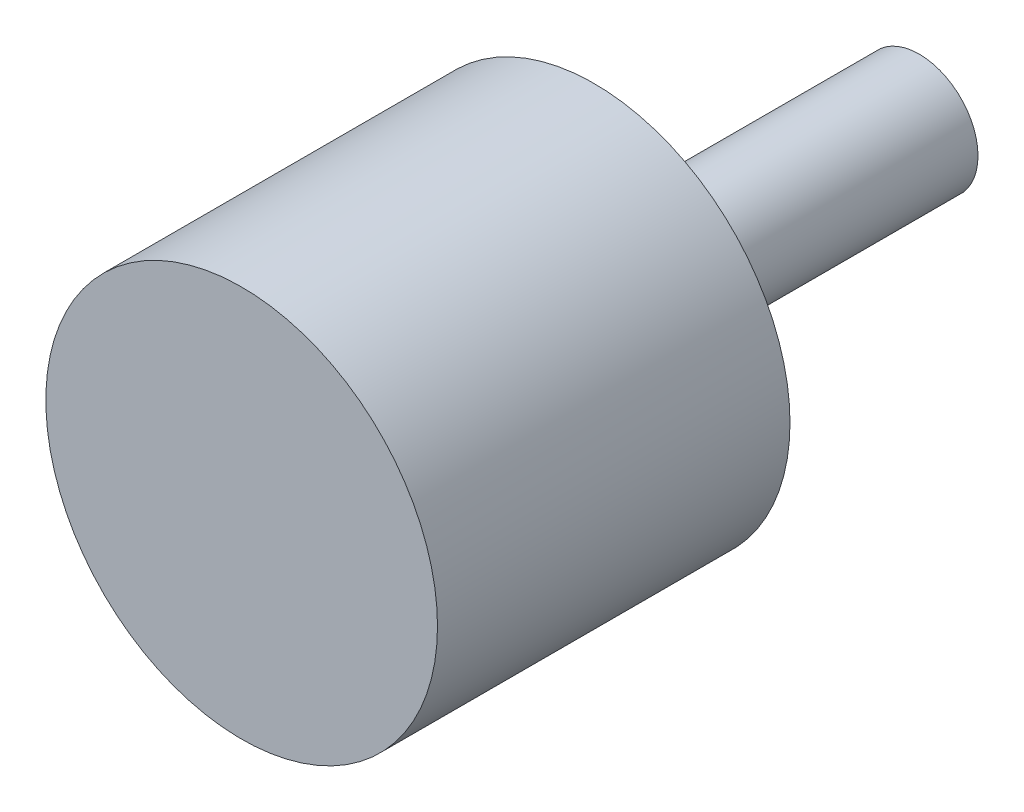
from build123d import *

# Parameters (mm, degrees)
SKETCH_1_R      = 5
EXTRUDE_1_DEPTH = 9
SKETCH_2_R      = 1.5
EXTRUDE_2_DEPTH = 8.3


with BuildPart() as part:
    # 草图1 → 凸台-拉伸1 (new body)
    with BuildSketch(Plane.XY):
        Circle(SKETCH_1_R)
    extrude(amount=EXTRUDE_1_DEPTH)

    # 草图2 → 凸台-拉伸2 (add)
    with BuildSketch(Plane(origin=(0, 0, 0), x_dir=(-1, 0, 0), z_dir=(0, 0, -1))):
        Circle(SKETCH_2_R)
    extrude(amount=EXTRUDE_2_DEPTH)


solid = part.part
